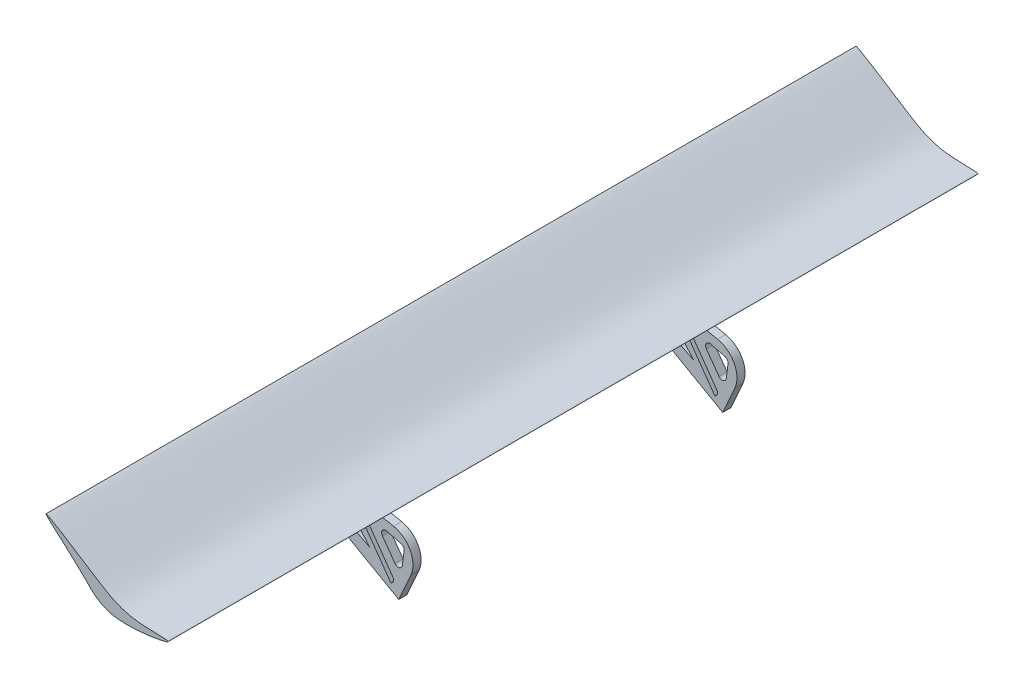
from build123d import *

# Parameters (mm, degrees)
BOSS_EXTRUDE1_DEPTH      = 254
BOSS_EXTRUDE1_DEPTH_BACK = 254
BOSS_EXTRUDE3_START      = 101.6
BOSS_EXTRUDE3_DEPTH      = 5.08
BOSS_EXTRUDE4_START      = -101.6
BOSS_EXTRUDE4_DEPTH      = 5.08


with BuildPart() as part:
    # Sketch1 → Boss-Extrude1 (new, two sides: drawn at the far end of the back side and taken through both)
    with BuildSketch(Plane.XY.offset(-BOSS_EXTRUDE1_DEPTH_BACK)):
        with BuildLine():
            add(Edge.make_bspline(
                [(0, 0), (-11.793525261, 1.349047136), (-19.975328866, 13.199555213), (-59.318204425, 45.322079961), (-9.910413221, 13.029756153), (5.495282291, 3.64818604), (45.436525366, 4.66810117), (12.884159615, -1.473803484), (0, 0)],
                knots=[0, 0, 0, 0, 0.168702633, 0.330072864, 0.529009501, 0.726907401, 0.815696189, 1, 1, 1, 1], degree=3))
        make_face()
    extrude(amount=BOSS_EXTRUDE1_DEPTH + BOSS_EXTRUDE1_DEPTH_BACK)

    # Sketch5 → Boss-Extrude3 (add)
    with BuildSketch(Plane.XY.offset(BOSS_EXTRUDE3_START)):
        with BuildLine():
            Line((-27.734991315, 18.72191959), (-16.264764371, -18.146559209))
            ThreePointArc((-16.264764371, -18.146559209), (-13.583203929, -23.176969331), (-9.240816118, -26.870133353))
            Line((-9.240816118, -26.870133353), (29.160917005, -48.686853663))
            Line((29.160917005, -48.686853663), (36.771225951, -31.668551915))
            ThreePointArc((36.771225951, -31.668551915), (36.410896446, -18.475716102), (25.887309714, -10.51111464))
            Line((25.887309714, -10.51111464), (14.191274323, -8.139664204))
            ThreePointArc((14.191274323, -8.139664204), (11.346694949, -7.26650899), (8.726002622, -5.857252601))
            Line((8.726002622, -5.857252601), (0, 0))
            Line((0, 0), (-27.734991315, 18.72191959))
        make_face()
        Polygon((-14.336909606, 0), (-8.034300835, -19.688978698), (11.0592478, -29.522672217), align=None, mode=Mode.SUBTRACT)
        with BuildLine():
            Line((24.250821237, -42.167199078), (1.466862058, -9.958744316))
            ThreePointArc((1.466862058, -9.958744316), (1.036984302, -8.062836909), (2.07362381, -6.418258448))
            Line((2.07362381, -6.418258448), (2.634761281, -6.021315057))
            Line((2.634761281, -6.021315057), (25.439170673, -38.258679182))
            ThreePointArc((25.439170673, -38.258679182), (25.855657312, -40.226490291), (24.710617564, -41.880160651))
            Line((24.710617564, -41.880160651), (24.250821237, -42.167199078))
        make_face(mode=Mode.SUBTRACT)
        with BuildLine():
            Line((21.569770125, -15.318563235), (30.625126067, -17.596266091))
            ThreePointArc((30.625126067, -17.596266091), (32.104548322, -18.62924079), (32.524728142, -20.383998852))
            Line((32.524728142, -20.383998852), (31.402279737, -29.098958991))
            ThreePointArc((31.402279737, -29.098958991), (29.507828706, -31.236468911), (26.823408491, -30.260876027))
            Line((26.823408491, -30.260876027), (18.890500955, -19.268213032))
            ThreePointArc((18.890500955, -19.268213032), (18.848182105, -16.355931543), (21.569770125, -15.318563235))
        make_face(mode=Mode.SUBTRACT)
    extrude(amount=BOSS_EXTRUDE3_DEPTH)

    # Sketch5_3 → Boss-Extrude4 (add)
    with BuildSketch(Plane.XY.offset(BOSS_EXTRUDE4_START)):
        with BuildLine():
            Line((-27.734991315, 18.72191959), (-16.264764371, -18.146559209))
            ThreePointArc((-16.264764371, -18.146559209), (-13.583203929, -23.176969331), (-9.240816118, -26.870133353))
            Line((-9.240816118, -26.870133353), (29.160917005, -48.686853663))
            Line((29.160917005, -48.686853663), (36.771225951, -31.668551915))
            ThreePointArc((36.771225951, -31.668551915), (36.410896446, -18.475716102), (25.887309714, -10.51111464))
            Line((25.887309714, -10.51111464), (14.191274323, -8.139664204))
            ThreePointArc((14.191274323, -8.139664204), (11.346694949, -7.26650899), (8.726002622, -5.857252601))
            Line((8.726002622, -5.857252601), (0, 0))
            Line((0, 0), (-27.734991315, 18.72191959))
        make_face()
        Polygon((-14.336909606, 0), (-8.034300835, -19.688978698), (11.0592478, -29.522672217), align=None, mode=Mode.SUBTRACT)
        with BuildLine():
            Line((24.250821237, -42.167199078), (1.466862058, -9.958744316))
            ThreePointArc((1.466862058, -9.958744316), (1.036984302, -8.062836909), (2.07362381, -6.418258448))
            Line((2.07362381, -6.418258448), (2.634761281, -6.021315057))
            Line((2.634761281, -6.021315057), (25.439170673, -38.258679182))
            ThreePointArc((25.439170673, -38.258679182), (25.855657312, -40.226490291), (24.710617564, -41.880160651))
            Line((24.710617564, -41.880160651), (24.250821237, -42.167199078))
        make_face(mode=Mode.SUBTRACT)
        with BuildLine():
            Line((21.569770125, -15.318563235), (30.625126067, -17.596266091))
            ThreePointArc((30.625126067, -17.596266091), (32.104548322, -18.62924079), (32.524728142, -20.383998852))
            Line((32.524728142, -20.383998852), (31.402279737, -29.098958991))
            ThreePointArc((31.402279737, -29.098958991), (29.507828706, -31.236468911), (26.823408491, -30.260876027))
            Line((26.823408491, -30.260876027), (18.890500955, -19.268213032))
            ThreePointArc((18.890500955, -19.268213032), (18.848182105, -16.355931543), (21.569770125, -15.318563235))
        make_face(mode=Mode.SUBTRACT)
    extrude(amount=BOSS_EXTRUDE4_DEPTH)


solid = part.part
